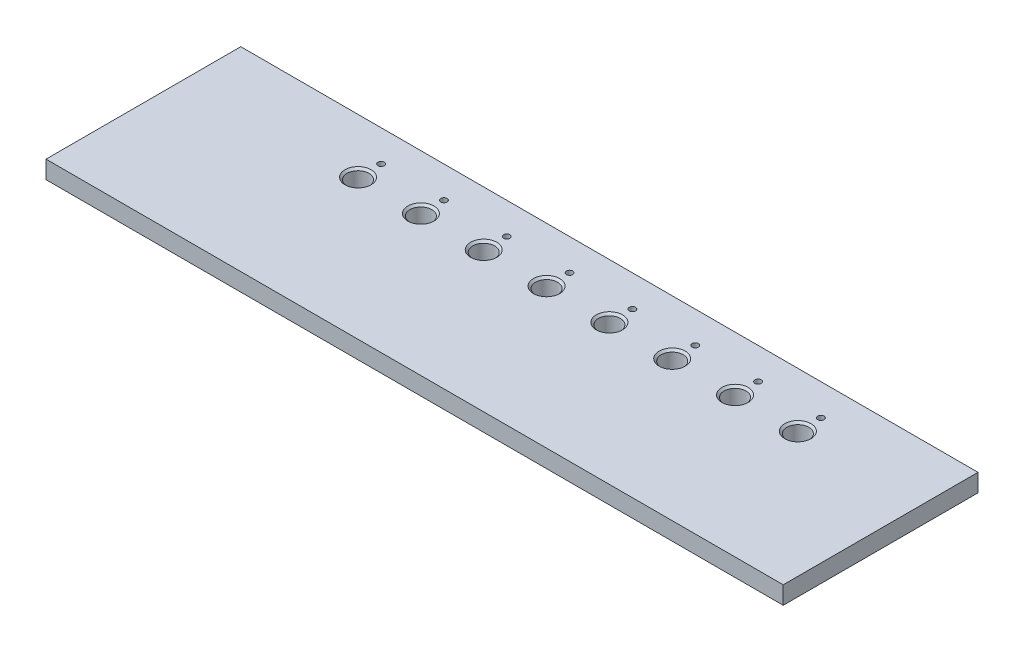
from build123d import *

# Parameters (mm, degrees)
ESQUISSE5_W             = 352
ESQUISSE5_H             = 93
BOSS_EXTRU_2_DEPTH      = 8.5
ESQUISSE3_R             = 1.5
ESQUISSE3_R_2           = 5.25
ENL_V_MAT_EXTRU_1_DEPTH = 9.5
CHANFREIN1_SIZE         = 1


with BuildPart() as part:
    # Esquisse5 → Boss.-Extru.2 (new body)
    with BuildSketch(Plane(origin=(0, 0, 0), x_dir=(1, 0, 0), z_dir=(0, 1, 0))):
        with Locations((5, -46.5)):
            Rectangle(ESQUISSE5_W, ESQUISSE5_H)
    extrude(amount=-BOSS_EXTRU_2_DEPTH)

    # Esquisse3 → Enlèv. mat.-Extru.1 (cut, through all)
    with BuildSketch(Plane(origin=(0, 0, 0), x_dir=(1, 0, 0), z_dir=(0, 1, 0))):
        with Locations((-89, -15)):
            Circle(ESQUISSE3_R)
        with Locations((-89, -26)):
            Circle(ESQUISSE3_R_2)
        with Locations((-59, -15)):
            Circle(ESQUISSE3_R)
        with Locations((-59, -26)):
            Circle(ESQUISSE3_R_2)
        with Locations((-29, -15)):
            Circle(ESQUISSE3_R)
        with Locations((-29, -26)):
            Circle(ESQUISSE3_R_2)
        with Locations((1, -15)):
            Circle(ESQUISSE3_R)
        with Locations((1, -26)):
            Circle(ESQUISSE3_R_2)
        with Locations((31, -15)):
            Circle(ESQUISSE3_R)
        with Locations((31, -26)):
            Circle(ESQUISSE3_R_2)
        with Locations((61, -15)):
            Circle(ESQUISSE3_R)
        with Locations((61, -26)):
            Circle(ESQUISSE3_R_2)
        with Locations((91, -15)):
            Circle(ESQUISSE3_R)
        with Locations((91, -26)):
            Circle(ESQUISSE3_R_2)
        with Locations((121, -15)):
            Circle(ESQUISSE3_R)
        with Locations((121, -26)):
            Circle(ESQUISSE3_R_2)
    extrude(amount=-ENL_V_MAT_EXTRU_1_DEPTH, mode=Mode.SUBTRACT)

    # Chanfrein1
    chanfrein1_edges = [part.edges().sort_by_distance(p)[0] for p in [
        (-34.25, 0, 26),
        (-4.25, 0, 26),
        (-94.25, 0, 26),
        (-64.25, 0, 26),
        (85.75, 0, 26),
        (115.75, 0, 26),
        (25.75, 0, 26),
        (55.75, 0, 26),
    ]]
    chamfer(chanfrein1_edges, length=CHANFREIN1_SIZE)


solid = part.part
